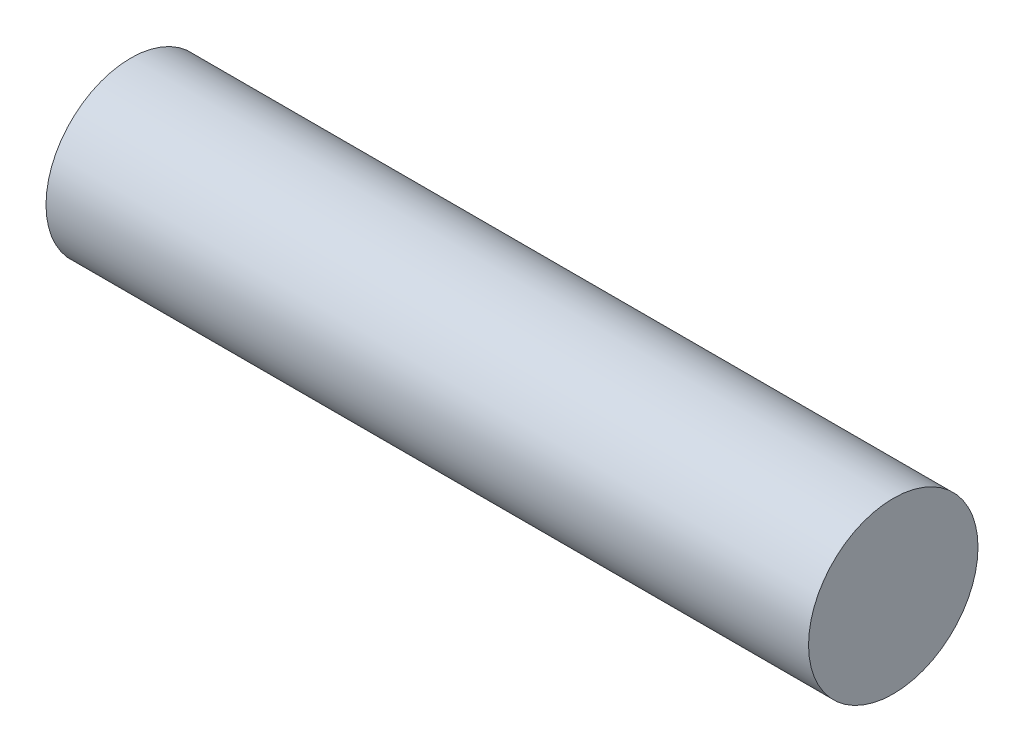
from build123d import *

# Parameters (mm, degrees)
SKETCH2_R           = 1
BOSS_EXTRUDE1_DEPTH = 9


with BuildPart() as part:
    # Sketch2 → Boss-Extrude1 (new body)
    with BuildSketch(Plane(origin=(0, 0, 0), x_dir=(0, 0, -1), z_dir=(1, 0, 0))):
        Circle(SKETCH2_R)
    extrude(amount=BOSS_EXTRUDE1_DEPTH)


solid = part.part
